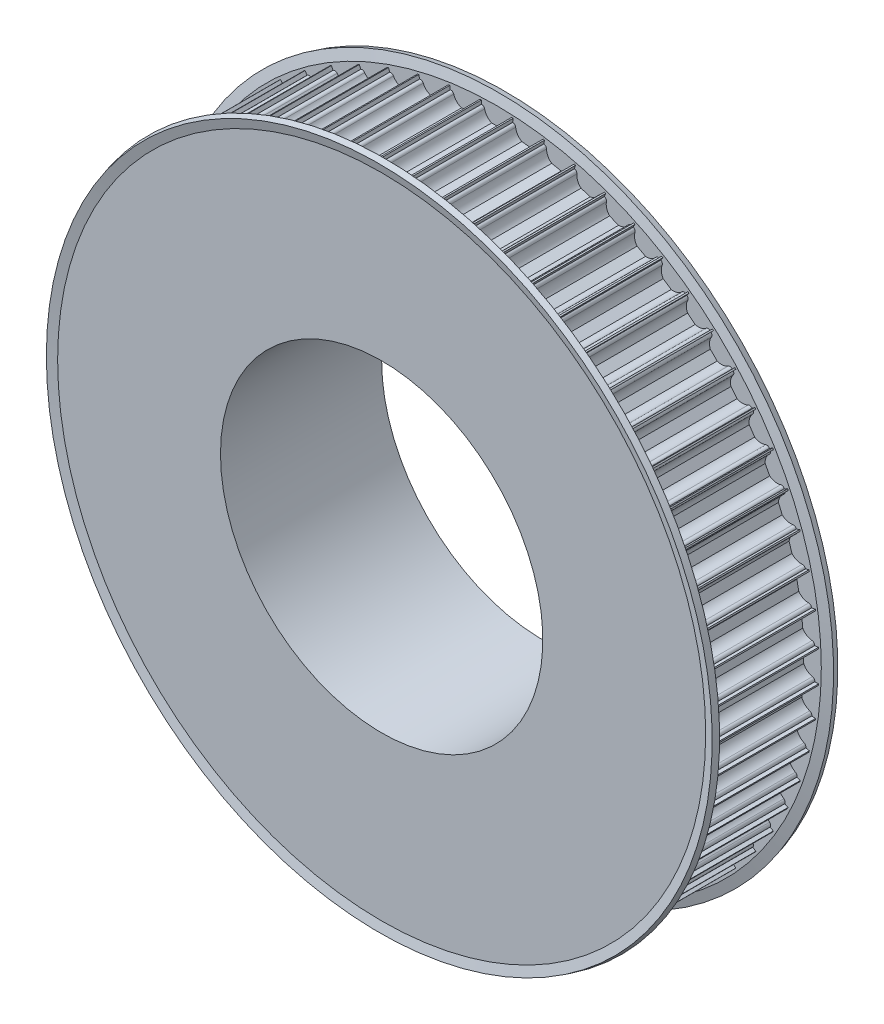
from build123d import *

# Parameters (mm, degrees)
CUT_EXTRUDE1_DEPTH = 41
CIRPATTERN1_COUNT  = 64


with BuildPart() as part:
    # Sketch1 → Revolve1 (revolve)
    with BuildSketch(Plane(origin=(0, 0, 0), x_dir=(0, 0, -1), z_dir=(1, 0, 0))):
        Polygon((0, 40), (0, 80), (30, 80), (30, 55.5), (40, 55.5), (40, 40), align=None)
    revolve(axis=Axis((0, 0, -88.99), (0, 0, 1)))

    # Sketch2 → Cut-Extrude1 (cut, through all)
    with BuildSketch(Plane.XY):
        with BuildLine():
            Line((3.674234614, 79), (3.75, 79))
            Line((3.75, 79), (3.75, 81))
            Line((3.75, 81), (-3.75, 81))
            Line((-3.75, 81), (-3.75, 79))
            Line((-3.75, 79), (-3.674234614, 79))
            ThreePointArc((-3.674234614, 79), (-3.199892965, 78.830947502), (-2.939387691, 78.4))
            ThreePointArc((-2.939387691, 78.4), (-2.331759211, 77.112435701), (-1.198957881, 76.25))
            Line((-1.198957881, 76.25), (1.198957881, 76.25))
            ThreePointArc((1.198957881, 76.25), (2.331759211, 77.112435701), (2.939387691, 78.4))
            ThreePointArc((2.939387691, 78.4), (3.199892965, 78.830947502), (3.674234614, 79))
        make_face()
    cut_extrude1 = extrude(amount=-CUT_EXTRUDE1_DEPTH, mode=Mode.SUBTRACT)

    # CirPattern1: Cut-Extrude1 ×64 about axis
    cirpattern1_axis = Axis((0, 0, 0), (0, 0, 1))
    for i in range(1, CIRPATTERN1_COUNT):
        add(cut_extrude1.rotate(cirpattern1_axis, i * 360 / CIRPATTERN1_COUNT), mode=Mode.SUBTRACT)

    # Sketch4 → Revolve2 (revolve)
    with BuildSketch(Plane(origin=(0, 0, 0), x_dir=(0, 0, -1), z_dir=(1, 0, 0))):
        Polygon((0, 80.414582296), (0, 75.612061042), (1.5, 75.612061042), (1.5, 80.612061042), (0.856921938, 83.012061042), (-0.591966801, 82.623832474), align=None)
        Polygon((30.591966801, 82.623832474), (29.143078062, 83.012061042), (28.5, 80.612061042), (28.5, 75.612061042), (30, 75.612061042), (30, 80.414582296), align=None)
    revolve(axis=Axis((0, 0, -88.99), (0, 0, 1)))


solid = part.part
